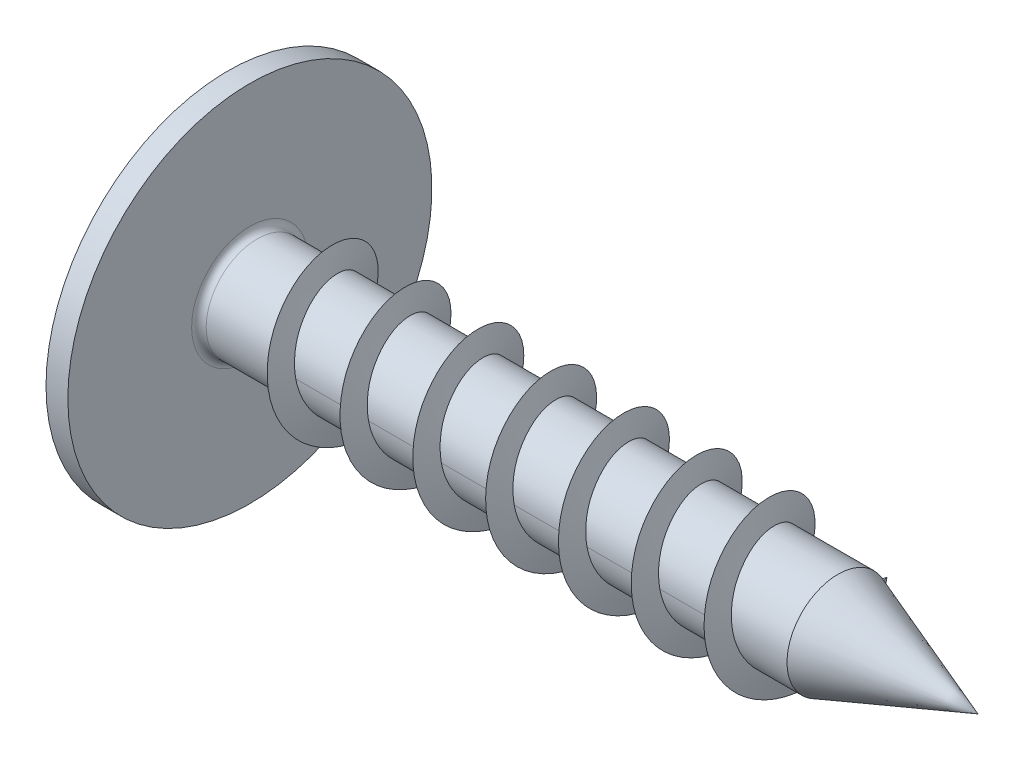
from build123d import *

# Parameters (mm, degrees)
FILLET1_R    = 0.1
SKETCH3_W    = 0.48
SKETCH3_H    = 2.1
SKETCH4_W    = 0.48
SKETCH4_H    = 0.68402847
RECPAT_COUNT = 2
RECPAT_ANGLE = 90


with BuildPart() as part:
    # BodySke → Base-Revolve (revolve)
    with BuildSketch(Plane.XY, mode=Mode.PRIVATE) as base_revolve_sk:
        with BuildLine():
            Line((1.3, 0.7), (1.3, 2.5))
            Line((1.3, 2.5), (1, 2.5))
            Line((1, 2.5), (1, 1.75))
            Line((1, 1.75), (0.620174425, 1.75))
            ThreePointArc((0.620174425, 1.75), (0.531980628, 1.726913525), (0.466409986, 1.663576159))
            ThreePointArc((0.466409986, 1.663576159), (0.118808019, 0.863861087), (0, 0))
            Line((0, 0), (11.3, 0))
            Line((11.3, 0), (9.376765806, 0.7))
            Line((9.376765806, 0.7), (1.3, 0.7))
        make_face()
    revolve(base_revolve_sk.sketch.rotate(Axis((-25.4, 0, 0), (1, 0, 0)), 90), axis=Axis((-25.4, 0, 0), (1, 0, 0)))

    # Fillet1
    fillet1_edges = [part.edges().sort_by_distance(p)[0] for p in [
        (1.3, 0, -0.7),
    ]]
    fillet(fillet1_edges, radius=FILLET1_R)

    # Sketch3 → Recess section 0
    with BuildSketch(Plane(origin=(0, 0, 0), x_dir=(0, 0, -1), z_dir=(1, 0, 0))):
        Rectangle(SKETCH3_W, SKETCH3_H)
    # Sketch4 → Recess section 1
    with BuildSketch(Plane(origin=(1.42, 0, 0), x_dir=(0, 0, -1), z_dir=(1, 0, 0))):
        Rectangle(SKETCH4_W, SKETCH4_H)
    recess = loft(mode=Mode.SUBTRACT)

    # RecPat: Recess ×2 about axis
    recpat_axis = Axis((0, 0, 0), (1, 0, 0))
    for i in range(1, RECPAT_COUNT):
        add(recess.rotate(recpat_axis, i * RECPAT_ANGLE / (RECPAT_COUNT - 1)), mode=Mode.SUBTRACT)

    # RecCorSke → RecessCore (revolve, cut)
    with BuildSketch(Plane.XY, mode=Mode.PRIVATE) as recesscore_sk:
        Polygon((0, 0), (0, 0.454796073), (1.42, 0.3555), (1.535508952, 0), align=None)
    revolve(recesscore_sk.sketch.rotate(Axis((-3.175, 0, 0), (1, 0, 0)), 13.894577695), axis=Axis((-3.175, 0, 0), (1, 0, 0)), mode=Mode.SUBTRACT)

    # Balayage1: sweep along a curve in space
    with BuildLine() as balayage1_path:
        add(Edge.make_bspline(
            [(1.8, -1, 0), (1.820703037, -1, -0.130081019), (1.862560471, -0.947931872, -0.393018011), (1.924983797, -0.725515645, -0.725416028), (1.987504342, -0.392646237, -0.947958564), (2.049998837, 0, -1.026026912), (2.112500312, 0.392646237, -0.947933788), (2.174999916, 0.725515645, -0.725515131), (2.237500022, 0.947931872, -0.392646375), (2.299999994, 1.026034064, 3.7e-08), (2.362500002, 0.947931872, 0.392646228), (2.425, 0.725515645, 0.725515647), (2.4875, 0.392646237, 0.947931871), (2.55, 0, 1.026034064), (2.6125, -0.392646237, 0.947931872), (2.675, -0.725515645, 0.725515645), (2.7375, -0.947931872, 0.392646237), (2.8, -1.026034064, 0), (2.8625, -0.947931872, -0.392646237), (2.925, -0.725515645, -0.725515645), (2.9875, -0.392646237, -0.947931872), (3.05, 0, -1.026034064), (3.1125, 0.392646237, -0.947931872), (3.175, 0.725515645, -0.725515645), (3.2375, 0.947931872, -0.392646237), (3.3, 1.026034064, 0), (3.3625, 0.947931872, 0.392646237), (3.425, 0.725515645, 0.725515645), (3.4875, 0.392646237, 0.947931872), (3.55, 0, 1.026034064), (3.6125, -0.392646237, 0.947931872), (3.675, -0.725515645, 0.725515645), (3.7375, -0.947931872, 0.392646237), (3.8, -1.026034064, 0), (3.8625, -0.947931872, -0.392646237), (3.925, -0.725515645, -0.725515645), (3.9875, -0.392646237, -0.947931872), (4.05, 0, -1.026034064), (4.1125, 0.392646237, -0.947931872), (4.175, 0.725515645, -0.725515645), (4.2375, 0.947931872, -0.392646237), (4.3, 1.026034064, 0), (4.3625, 0.947931872, 0.392646237), (4.425, 0.725515645, 0.725515645), (4.4875, 0.392646237, 0.947931872), (4.55, 0, 1.026034064), (4.6125, -0.392646237, 0.947931872), (4.675, -0.725515645, 0.725515645), (4.7375, -0.947931872, 0.392646237), (4.8, -1.026034064, 0), (4.8625, -0.947931872, -0.392646237), (4.925, -0.725515645, -0.725515645), (4.9875, -0.392646237, -0.947931872), (5.05, 0, -1.026034064), (5.1125, 0.392646237, -0.947931872), (5.175, 0.725515645, -0.725515645), (5.2375, 0.947931872, -0.392646237), (5.3, 1.026034064, 0), (5.3625, 0.947931872, 0.392646237), (5.425, 0.725515645, 0.725515645), (5.4875, 0.392646237, 0.947931872), (5.55, 0, 1.026034064), (5.6125, -0.392646237, 0.947931872), (5.675, -0.725515645, 0.725515645), (5.7375, -0.947931872, 0.392646237), (5.8, -1.026034064, 0), (5.8625, -0.947931872, -0.392646237), (5.925, -0.725515645, -0.725515645), (5.9875, -0.392646237, -0.947931872), (6.05, 0, -1.026034064), (6.1125, 0.392646237, -0.947931872), (6.175, 0.725515645, -0.725515645), (6.2375, 0.947931872, -0.392646237), (6.3, 1.026034064, 0), (6.3625, 0.947931872, 0.392646237), (6.425, 0.725515645, 0.725515645), (6.4875, 0.392646237, 0.947931872), (6.55, 0, 1.026034064), (6.6125, -0.392646237, 0.947931872), (6.675, -0.725515645, 0.725515645), (6.7375, -0.947931872, 0.392646237), (6.8, -1.026034064, 0), (6.8625, -0.947931872, -0.392646237), (6.925, -0.725515645, -0.725515645), (6.9875, -0.392646237, -0.947931872), (7.05, 0, -1.026034064), (7.1125, 0.392646237, -0.947931872), (7.175, 0.725515645, -0.725515645), (7.2375, 0.947931872, -0.392646237), (7.3, 1.026034064, 0), (7.3625, 0.947931872, 0.392646237), (7.425, 0.725515645, 0.725515645), (7.4875, 0.392646237, 0.947931872), (7.55, 0, 1.026034064), (7.6125, -0.392646237, 0.947931872), (7.675, -0.725515645, 0.725515645), (7.7375, -0.947931872, 0.392646237), (7.8, -1.026034064, 0), (7.8625, -0.947931872, -0.392646237), (7.925, -0.725515645, -0.725515645), (7.9875, -0.392646237, -0.947931872), (8.05, 0, -1.026034064), (8.1125, 0.392646237, -0.947931872), (8.175, 0.725515645, -0.725515645), (8.2375, 0.947931872, -0.392646237), (8.3, 1.026034064, 0), (8.3625, 0.947931871, 0.392646237), (8.425, 0.725515647, 0.725515645), (8.487499998, 0.392646228, 0.947931872), (8.550000006, 3.7e-08, 1.026034064), (8.612499978, -0.392646375, 0.947931872), (8.675000084, -0.725515131, 0.725515645), (8.737499688, -0.947933788, 0.392646237), (8.800001163, -1.026026912, 0), (8.862495658, -0.947958564, -0.392646237), (8.925016203, -0.725416028, -0.725515645), (8.987439529, -0.393018011, -0.947931872), (9.029296963, -0.130081019, -1), (9.05, 0, -1)],
            knots=[0, 0, 0, 0, 0.00862069, 0.017241379, 0.025862069, 0.034482759, 0.043103448, 0.051724138, 0.060344828, 0.068965517, 0.077586207, 0.086206897, 0.094827586, 0.103448276, 0.112068966, 0.120689655, 0.129310345, 0.137931034, 0.146551724, 0.155172414, 0.163793103, 0.172413793, 0.181034483, 0.189655172, 0.198275862, 0.206896552, 0.215517241, 0.224137931, 0.232758621, 0.24137931, 0.25, 0.25862069, 0.267241379, 0.275862069, 0.284482759, 0.293103448, 0.301724138, 0.310344828, 0.318965517, 0.327586207, 0.336206897, 0.344827586, 0.353448276, 0.362068966, 0.370689655, 0.379310345, 0.387931034, 0.396551724, 0.405172414, 0.413793103, 0.422413793, 0.431034483, 0.439655172, 0.448275862, 0.456896552, 0.465517241, 0.474137931, 0.482758621, 0.49137931, 0.5, 0.50862069, 0.517241379, 0.525862069, 0.534482759, 0.543103448, 0.551724138, 0.560344828, 0.568965517, 0.577586207, 0.586206897, 0.594827586, 0.603448276, 0.612068966, 0.620689655, 0.629310345, 0.637931034, 0.646551724, 0.655172414, 0.663793103, 0.672413793, 0.681034483, 0.689655172, 0.698275862, 0.706896552, 0.715517241, 0.724137931, 0.732758621, 0.74137931, 0.75, 0.75862069, 0.767241379, 0.775862069, 0.784482759, 0.793103448, 0.801724138, 0.810344828, 0.818965517, 0.827586207, 0.836206897, 0.844827586, 0.853448276, 0.862068966, 0.870689655, 0.879310345, 0.887931034, 0.896551724, 0.905172414, 0.913793103, 0.922413793, 0.931034483, 0.939655172, 0.948275862, 0.956896552, 0.965517241, 0.974137931, 0.982758621, 0.99137931, 1, 1, 1, 1], degree=3))
    with BuildLine() as balayage1_axis:
        Line((1.8, 0, 0), (9.05, 0, 0))
    # Esquisse2 → Balayage1 (sweep)
    with BuildSketch(Plane.XY):
        Polygon((1.719615242, -0.7), (1.8, -1), (1.880384758, -0.7), align=None)
    sweep(path=balayage1_path.line, binormal=balayage1_axis.edges()[0])


solid = part.part
